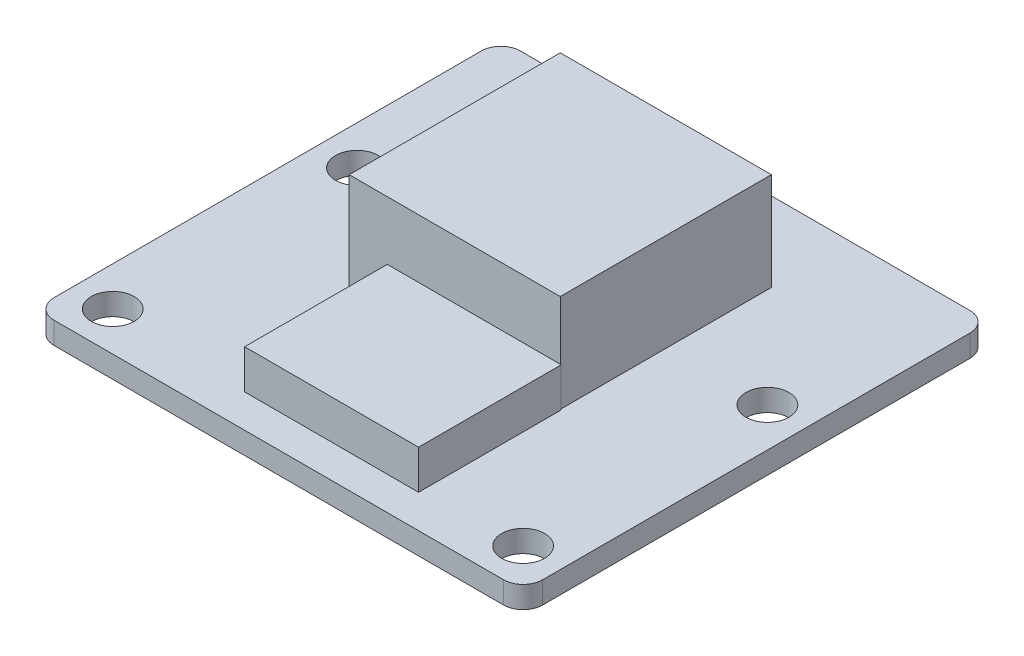
from build123d import *

# Parameters (mm, degrees)
SKETCH1_W           = 25
SKETCH1_H           = 23.862
BOSS_EXTRUDE1_DEPTH = 1.12
FILLET1_R           = 1
SKETCH2_R           = 1.1
CUT_EXTRUDE1_DEPTH  = 2
SKETCH3_W           = 10.8
SKETCH3_H           = 10.8
BOSS_EXTRUDE2_DEPTH = 5
SKETCH4_W           = 8.9
SKETCH4_H           = 7.3
BOSS_EXTRUDE3_DEPTH = 2


with BuildPart() as part:
    # Sketch1 → Boss-Extrude1 (new body)
    with BuildSketch(Plane(origin=(0, 0, 0), x_dir=(1, 0, 0), z_dir=(0, 1, 0))):
        Rectangle(SKETCH1_W, SKETCH1_H)
    extrude(amount=BOSS_EXTRUDE1_DEPTH)

    # Fillet1
    fillet1_edges = [part.edges().sort_by_distance(p)[0] for p in [
        (-12.5, 0.56, -11.931),
        (12.5, 0.56, -11.931),
        (12.5, 0.56, 11.931),
        (-12.5, 0.56, 11.931),
    ]]
    fillet(fillet1_edges, radius=FILLET1_R)

    # Sketch2 → Cut-Extrude1 (cut)
    with BuildSketch(Plane(origin=(0, 1.12, 0), x_dir=(1, 0, 0), z_dir=(0, 1, 0))):
        with Locations((-10.5, 2.569)):
            Circle(SKETCH2_R)
        with Locations((10.5, 2.569)):
            Circle(SKETCH2_R)
        with Locations((-10.5, -9.931)):
            Circle(SKETCH2_R)
        with Locations((10.5, -9.931)):
            Circle(SKETCH2_R)
    extrude(amount=-CUT_EXTRUDE1_DEPTH, mode=Mode.SUBTRACT)

    # Sketch3 → Boss-Extrude2 (add)
    with BuildSketch(Plane(origin=(0, 1.12, 0), x_dir=(1, 0, 0), z_dir=(0, 1, 0))):
        with Locations((0, 2.469)):
            Rectangle(SKETCH3_W, SKETCH3_H)
    extrude(amount=BOSS_EXTRUDE2_DEPTH)

    # Sketch4 → Boss-Extrude3 (add)
    with BuildSketch(Plane(origin=(0, 1.12, 0), x_dir=(1, 0, 0), z_dir=(0, 1, 0))):
        with Locations((1, -6.581)):
            Rectangle(SKETCH4_W, SKETCH4_H)
    extrude(amount=BOSS_EXTRUDE3_DEPTH)


solid = part.part
